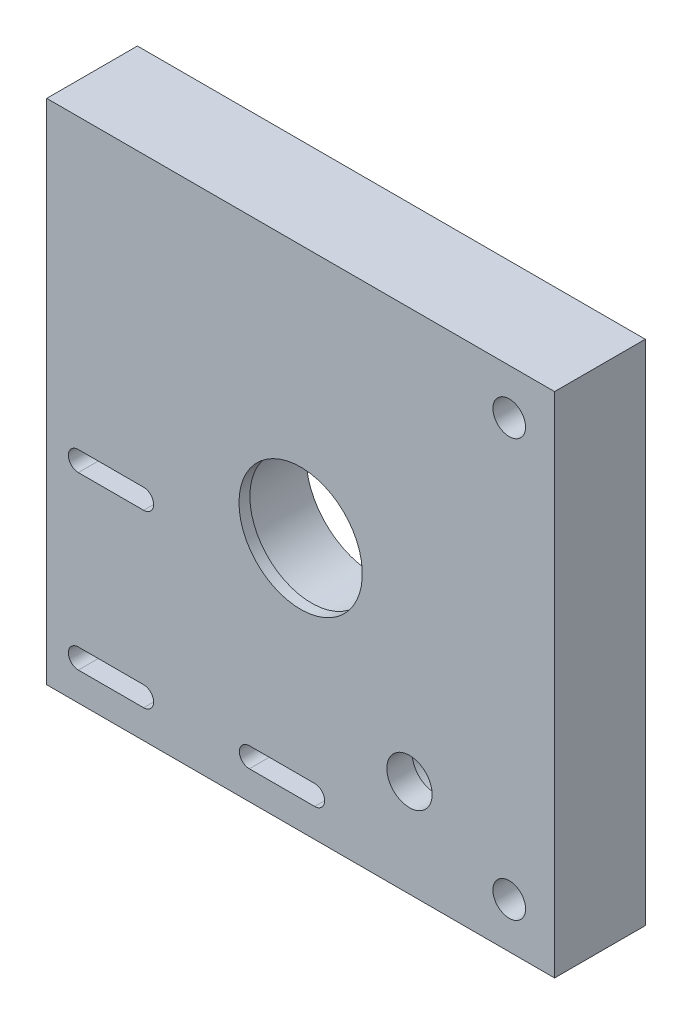
from build123d import *

# Parameters (mm, degrees)
ESQUISSE1_W                                        = 150
ESQUISSE1_H                                        = 150
BOSS_EXTRU_1_DEPTH                                 = 25
CHAMBRAGE_POUR_VIS_T_TE_HEXAGONALE_M81_D           = 9
CHAMBRAGE_POUR_VIS_T_TE_HEXAGONALE_M81_CBORE_D     = 15
CHAMBRAGE_POUR_VIS_T_TE_HEXAGONALE_M81_CBORE_DEPTH = 8.6
CHAMBRAGE_POUR_VIS_T_TE_HEXAGONALE_M51_D           = 5.5
CHAMBRAGE_POUR_VIS_T_TE_HEXAGONALE_M51_CBORE_D     = 10
CHAMBRAGE_POUR_VIS_T_TE_HEXAGONALE_M51_CBORE_DEPTH = 5.4
ESQUISSE13_R                                       = 18.5
ENL_V_MAT_EXTRU_1_DEPTH                            = 22
ESQUISSE14_R                                       = 17
ENL_V_MAT_EXTRU_2_DEPTH                            = 4
ESQUISSE31_R                                       = 33
ENL_V_MAT_EXTRU_11_DEPTH                           = 5
TROU_POUR_TARAUDAGE_POUR_TROU_TARAUD_M6_D          = 5
TROU_POUR_TARAUDAGE_POUR_TROU_TARAUD_M6_DEPTH      = 16
TROU_POUR_TARAUDAGE_POUR_TROU_TARAUD_M6_TIP        = 1.502151548
ESQUISSE27_R                                       = 11
ENL_V_MAT_EXTRU_7_DEPTH                            = 18
ESQUISSE28_R                                       = 6.25
ENL_V_MAT_EXTRU_8_DEPTH                            = 8
ENL_V_MAT_EXTRU_9_DEPTH                            = 20.6
ENL_V_MAT_EXTRU_10_DEPTH                           = 5.4
ESQUISSE32_R                                       = 129.983308099
ESQUISSE32_W                                       = 140
ESQUISSE32_H                                       = 140
ENL_V_MAT_EXTRU_12_DEPTH                           = 26


with BuildPart() as part:
    # Esquisse1 → Boss.-Extru.1 (new body)
    with BuildSketch(Plane.XY):
        Rectangle(ESQUISSE1_W, ESQUISSE1_H)
    extrude(amount=BOSS_EXTRU_1_DEPTH)

    # Chambrage pour vis à tête hexagonale M81 (through all)
    with Locations(Plane(origin=(0, 0, 0), x_dir=(-1, 0, 0), z_dir=(0, 0, -1))):
        with Locations((-57.5, -57.5), (-57.5, 57.5)):
            CounterBoreHole(CHAMBRAGE_POUR_VIS_T_TE_HEXAGONALE_M81_D / 2, CHAMBRAGE_POUR_VIS_T_TE_HEXAGONALE_M81_CBORE_D / 2, CHAMBRAGE_POUR_VIS_T_TE_HEXAGONALE_M81_CBORE_DEPTH)

    # Chambrage pour vis à tête hexagonale M51 (through all)
    with Locations(Plane(origin=(0, 0, 0), x_dir=(-1, 0, 0), z_dir=(0, 0, -1))):
        with Locations((14.144188312, -59.37), (61.284188312, -59.37), (61.284188312, -12.23)):
            CounterBoreHole(CHAMBRAGE_POUR_VIS_T_TE_HEXAGONALE_M51_D / 2, CHAMBRAGE_POUR_VIS_T_TE_HEXAGONALE_M51_CBORE_D / 2, CHAMBRAGE_POUR_VIS_T_TE_HEXAGONALE_M51_CBORE_DEPTH)

    # Esquisse13 → Enlèv. mat.-Extru.1 (cut)
    with BuildSketch(Plane.XY):
        Circle(ESQUISSE13_R)
    extrude(amount=ENL_V_MAT_EXTRU_1_DEPTH, mode=Mode.SUBTRACT)

    # Esquisse14 → Enlèv. mat.-Extru.2 (cut, through all)
    with BuildSketch(Plane(origin=(0, 0, 22), x_dir=(-1, 0, 0), z_dir=(0, 0, -1))):
        Circle(ESQUISSE14_R)
    extrude(amount=-ENL_V_MAT_EXTRU_2_DEPTH, mode=Mode.SUBTRACT)

    # Esquisse31 → Enlèv. mat.-Extru.11 (cut)
    with BuildSketch(Plane(origin=(0, 0, 0), x_dir=(-1, 0, 0), z_dir=(0, 0, -1))):
        Circle(ESQUISSE31_R)
    extrude(amount=-ENL_V_MAT_EXTRU_11_DEPTH, mode=Mode.SUBTRACT)

    # Trou pour taraudage pour trou taraudé M61
    with Locations(Plane(origin=(0, 0, 5), x_dir=(1, 0, 0), z_dir=(0, 0, -1))):
        with Locations((0, 25), (-25, 0), (0, -25), (25, 0), (0, 0)):
            Hole(TROU_POUR_TARAUDAGE_POUR_TROU_TARAUD_M6_D / 2, depth=TROU_POUR_TARAUDAGE_POUR_TROU_TARAUD_M6_DEPTH)
            with Locations((0, 0, -(TROU_POUR_TARAUDAGE_POUR_TROU_TARAUD_M6_DEPTH + TROU_POUR_TARAUDAGE_POUR_TROU_TARAUD_M6_TIP / 2))):  # 118° drill point
                Cone(0, TROU_POUR_TARAUDAGE_POUR_TROU_TARAUD_M6_D / 2, TROU_POUR_TARAUDAGE_POUR_TROU_TARAUD_M6_TIP, mode=Mode.SUBTRACT)

    # Esquisse27 → Enlèv. mat.-Extru.7 (cut)
    with BuildSketch(Plane(origin=(0, 0, 0), x_dir=(-1, 0, 0), z_dir=(0, 0, -1))):
        with Locations((-30, -43.084219849)):
            Circle(ESQUISSE27_R)
    extrude(amount=-ENL_V_MAT_EXTRU_7_DEPTH, mode=Mode.SUBTRACT)

    # Esquisse28 → Enlèv. mat.-Extru.8 (cut, through all)
    with BuildSketch(Plane(origin=(0, 0, 18), x_dir=(-1, 0, 0), z_dir=(0, 0, -1))):
        with Locations((-30, -43.084219849)):
            Circle(ESQUISSE28_R)
    extrude(amount=-ENL_V_MAT_EXTRU_8_DEPTH, mode=Mode.SUBTRACT)

    # Esquisse29 → Enlèv. mat.-Extru.9 (cut, through all)
    with BuildSketch(Plane(origin=(0, 0, 5.4), x_dir=(-1, 0, 0), z_dir=(0, 0, -1))):
        with BuildLine():
            Line((61.284188312, -62.12), (43.284188312, -62.12))
            ThreePointArc((43.284188312, -62.12), (40.534188312, -59.37), (43.284188312, -56.62))
            Line((43.284188312, -56.62), (61.284188312, -56.62))
            ThreePointArc((61.284188312, -56.62), (64.034188312, -59.37), (61.284188312, -62.12))
        make_face()
        with BuildLine():
            Line((14.144188312, -62.12), (-3.855811688, -62.12))
            ThreePointArc((-3.855811688, -62.12), (-6.605811688, -59.37), (-3.855811688, -56.62))
            Line((-3.855811688, -56.62), (14.144188312, -56.62))
            ThreePointArc((14.144188312, -56.62), (16.894188312, -59.37), (14.144188312, -62.12))
        make_face()
        with BuildLine():
            Line((61.284188312, -14.98), (43.284188312, -14.98))
            ThreePointArc((43.284188312, -14.98), (40.534188312, -12.23), (43.284188312, -9.48))
            Line((43.284188312, -9.48), (61.284188312, -9.48))
            ThreePointArc((61.284188312, -9.48), (64.034188312, -12.23), (61.284188312, -14.98))
        make_face()
    extrude(amount=-ENL_V_MAT_EXTRU_9_DEPTH, mode=Mode.SUBTRACT)

    # Esquisse30 → Enlèv. mat.-Extru.10 (cut)
    with BuildSketch(Plane(origin=(0, 0, 0), x_dir=(-1, 0, 0), z_dir=(0, 0, -1))):
        with BuildLine():
            Line((-3.855811688, -64.37), (14.144188312, -64.37))
            ThreePointArc((14.144188312, -64.37), (19.144188312, -59.37), (14.144188312, -54.37))
            Line((14.144188312, -54.37), (-3.855811688, -54.37))
            ThreePointArc((-3.855811688, -54.37), (-8.855811688, -59.37), (-3.855811688, -64.37))
        make_face()
        with BuildLine():
            Line((43.284188312, -64.37), (61.284188312, -64.37))
            ThreePointArc((61.284188312, -64.37), (66.284188312, -59.37), (61.284188312, -54.37))
            Line((61.284188312, -54.37), (43.284188312, -54.37))
            ThreePointArc((43.284188312, -54.37), (38.284188312, -59.37), (43.284188312, -64.37))
        make_face()
        with BuildLine():
            Line((43.284188312, -17.23), (61.284188312, -17.23))
            ThreePointArc((61.284188312, -17.23), (66.284188312, -12.23), (61.284188312, -7.23))
            Line((61.284188312, -7.23), (43.284188312, -7.23))
            ThreePointArc((43.284188312, -7.23), (38.284188312, -12.23), (43.284188312, -17.23))
        make_face()
    extrude(amount=-ENL_V_MAT_EXTRU_10_DEPTH, mode=Mode.SUBTRACT)

    # Esquisse32 → Enlèv. mat.-Extru.12 (cut, through all)
    with BuildSketch(Plane(origin=(0, 0, 0), x_dir=(-1, 0, 0), z_dir=(0, 0, -1))):
        Circle(ESQUISSE32_R)
        Rectangle(ESQUISSE32_W, ESQUISSE32_H, mode=Mode.SUBTRACT)
    extrude(amount=-ENL_V_MAT_EXTRU_12_DEPTH, mode=Mode.SUBTRACT)


solid = part.part
